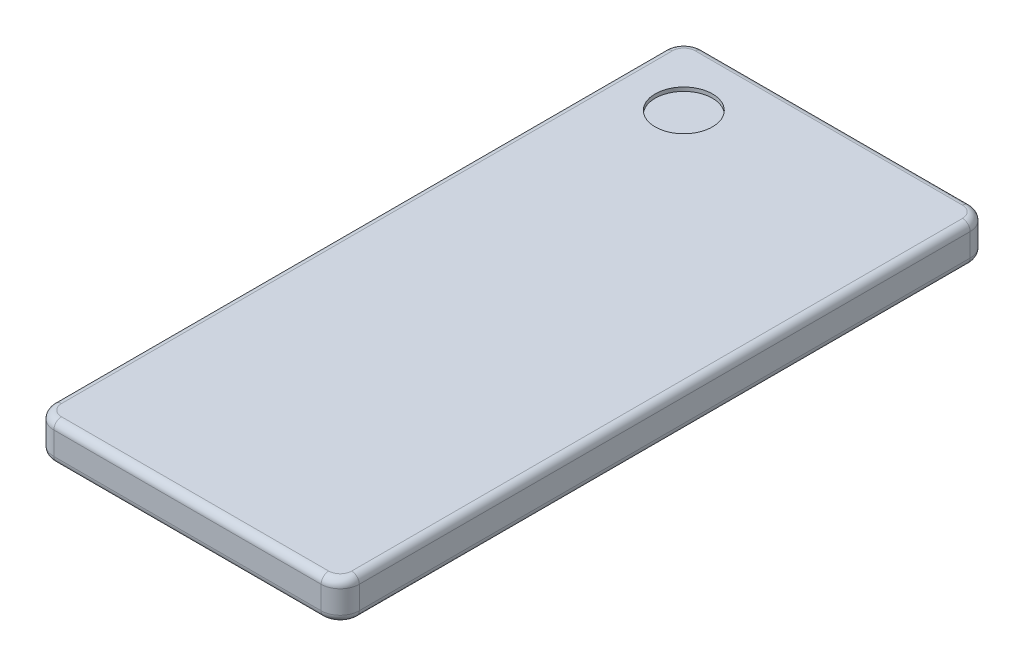
from build123d import *

# Parameters (mm, degrees)
SKETCH1_W           = 80
SKETCH1_H           = 170
BOSS_EXTRUDE1_DEPTH = 10
FILLET4_R           = 5
FILLET5_R           = 2
SKETCH3_R           = 7.5
CUT_EXTRUDE1_DEPTH  = 1


with BuildPart() as part:
    # Sketch1 → Boss-Extrude1 (new body)
    with BuildSketch(Plane(origin=(0, 0, 0), x_dir=(1, 0, 0), z_dir=(0, 1, 0))):
        Rectangle(SKETCH1_W, SKETCH1_H)
    extrude(amount=BOSS_EXTRUDE1_DEPTH)

    # Fillet4
    fillet4_edges = [part.edges().sort_by_distance(p)[0] for p in [
        (40, 5, 85),
        (-40, 5, 85),
        (-40, 5, -85),
        (40, 5, -85),
    ]]
    fillet(fillet4_edges, radius=FILLET4_R)

    # Fillet5
    fillet5_edges = [part.edges().sort_by_distance(p)[0] for p in [
        (0, 0, -85),
        (0, 10, -85),
        (40, 0, 0),
        (0, 0, 85),
        (-40, 0, 0),
        (38.535533906, 0, 83.535533906),
        (-38.535533906, 0, 83.535533906),
        (-38.535533906, 0, -83.535533906),
        (38.535533906, 0, -83.535533906),
        (40, 10, 0),
        (-40, 10, 0),
        (0, 10, 85),
        (38.535533906, 10, 83.535533906),
        (-38.535533906, 10, 83.535533906),
        (-38.535533906, 10, -83.535533906),
        (38.535533906, 10, -83.535533906),
    ]]
    fillet(fillet5_edges, radius=FILLET5_R)

    # Sketch3 → Cut-Extrude1 (cut)
    with BuildSketch(Plane(origin=(0, 10, 0), x_dir=(1, 0, 0), z_dir=(0, 1, 0))):
        with Locations((-23, 68)):
            Circle(SKETCH3_R)
    extrude(amount=-CUT_EXTRUDE1_DEPTH, mode=Mode.SUBTRACT)


solid = part.part
